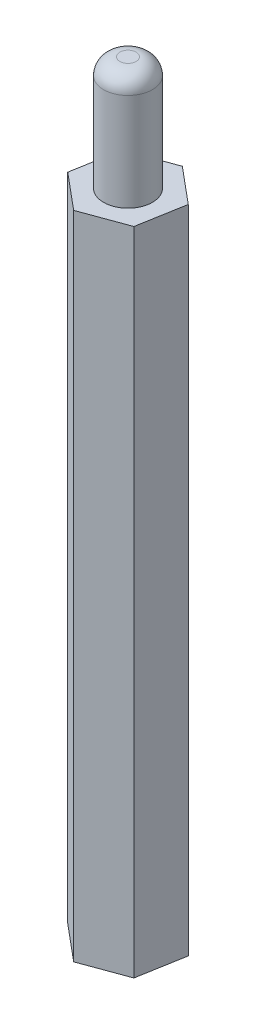
from build123d import *

# Parameters (mm, degrees)
BOSS_EXTRUDE1_DEPTH = 40
SKETCH2_R           = 1.5
BOSS_EXTRUDE2_DEPTH = 7
SKETCH3_R           = 1.5
CUT_EXTRUDE1_DEPTH  = 7
FILLET1_R           = 1


with BuildPart() as part:
    # Sketch1 → Boss-Extrude1 (new body)
    with BuildSketch(Plane(origin=(0, 0, 0), x_dir=(1, 0, 0), z_dir=(0, 1, 0))):
        Polygon((2.214824591, -1.851454932), (2.7108193, 0.992366895), (0.495994709, 2.843821827), (-2.214824591, 1.851454932), (-2.7108193, -0.992366895), (-0.495994709, -2.843821827), align=None)
    extrude(amount=BOSS_EXTRUDE1_DEPTH)

    # Sketch2 → Boss-Extrude2 (add)
    with BuildSketch(Plane(origin=(0, 40, 0), x_dir=(1, 0, 0), z_dir=(0, 1, 0))):
        Circle(SKETCH2_R)
    extrude(amount=BOSS_EXTRUDE2_DEPTH)

    # Sketch3 → Cut-Extrude1 (cut)
    with BuildSketch(Plane.XZ):
        Circle(SKETCH3_R)
    extrude(amount=-CUT_EXTRUDE1_DEPTH, mode=Mode.SUBTRACT)

    # Fillet1
    fillet1_edges = [part.edges().sort_by_distance(p)[0] for p in [
        (-1.5, 47, 0),
    ]]
    fillet(fillet1_edges, radius=FILLET1_R)


solid = part.part
